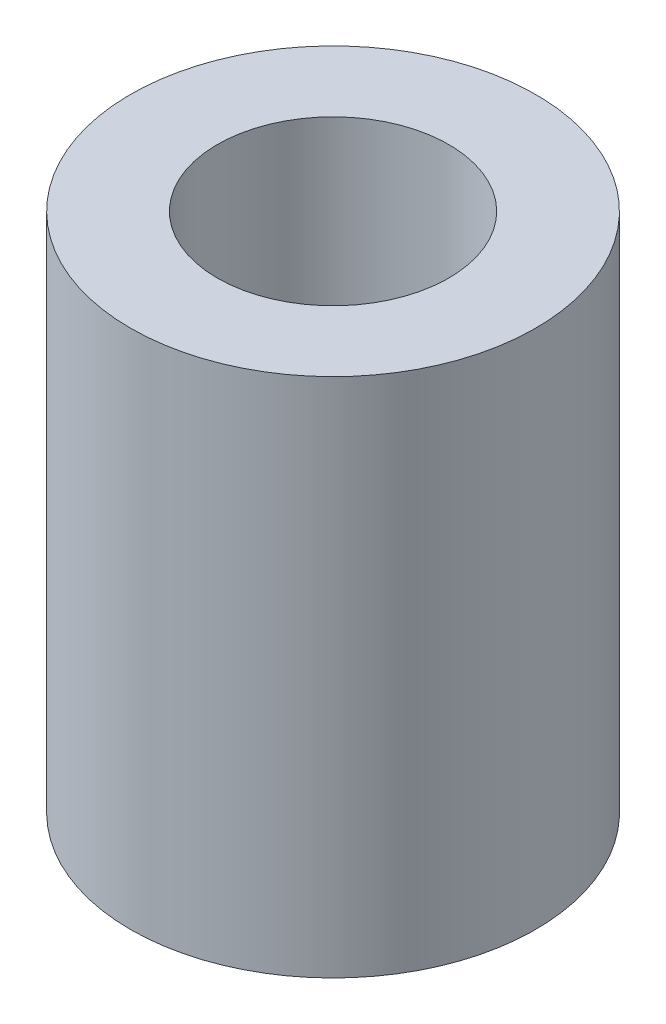
from build123d import *

# Parameters (mm, degrees)
SKETCH1_R           = 17.5
SKETCH1_R_2         = 10
BOSS_EXTRUDE1_DEPTH = 45


with BuildPart() as part:
    # Sketch1 → Boss-Extrude1 (new body)
    with BuildSketch(Plane(origin=(0, 0, 0), x_dir=(1, 0, 0), z_dir=(0, 1, 0))):
        Circle(SKETCH1_R)
        Circle(SKETCH1_R_2, mode=Mode.SUBTRACT)
    extrude(amount=BOSS_EXTRUDE1_DEPTH)


solid = part.part
